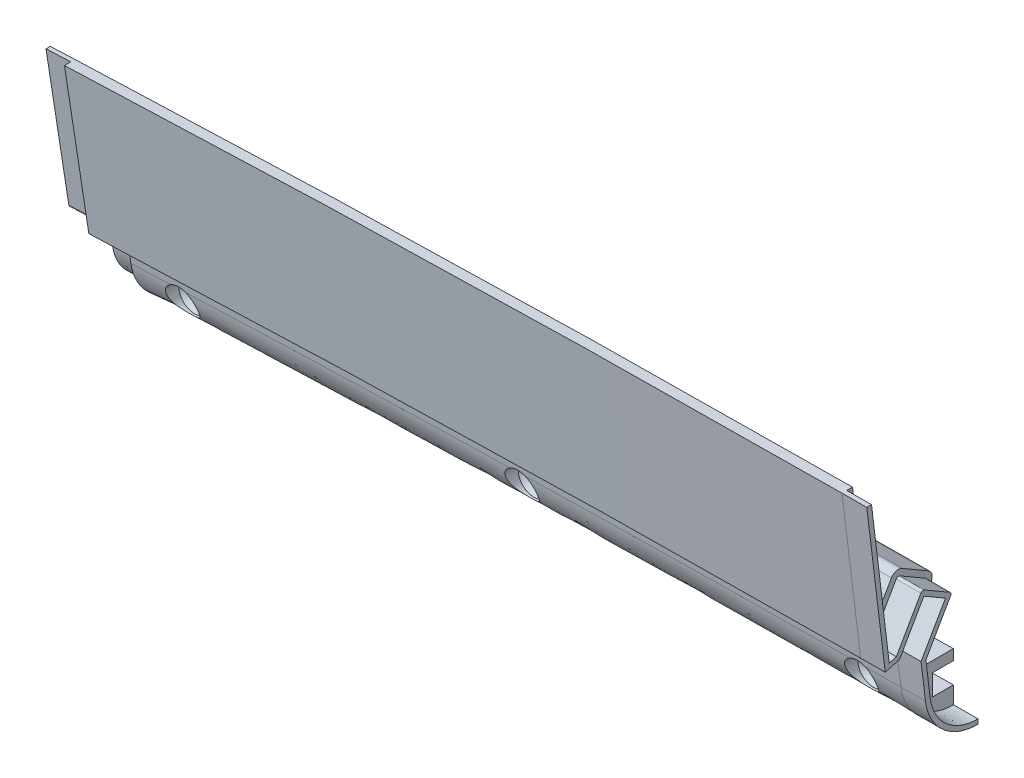
from build123d import *


with BuildPart() as part:
    # Sweep3: sweep along a path in Sketch3
    with BuildLine(Plane.XY.offset(101.6)) as sweep3_path:
        ThreePointArc((622.103936151, -83.199836272), (0, -43.636564626), (-622.103936151, -83.199836272))
    # Sketch4 → Sweep3 (sweep)
    with BuildSketch(Plane(origin=(-117.330566703, 4.430423936, 1117.6), x_dir=(0, 0, -1), z_dir=(0.9994536405585157, 0.03305178322465143, 0))):
        with BuildLine():
            Line((991.529482971, -5.453775083), (988.971801376, -5.453775083))
            Line((988.971801376, -5.453775083), (993.32506615, -42.283775083))
            Line((993.32506615, -42.283775083), (996.794703229, -41.354088728))
            Line((996.794703229, -41.354088728), (1002.763703229, -31.015013775))
            Line((1002.763703229, -31.015013775), (1007.999, -34.037749136))
            Line((1007.999, -34.037749136), (1002.03, -44.376824659))
            Line((1002.03, -44.376824659), (1003.077032208, -53.235049058))
            ThreePointArc((1003.077032208, -53.235049058), (1007.29752688, -61.276835992), (1015.8095, -64.443731312))
            Line((1015.8095, -64.443731312), (1015.8095, -59.12218153))
            Line((1015.8095, -59.12218153), (1010.7295, -59.12218153))
            Line((1010.7295, -59.12218153), (1010.7295, -54.041969025))
            Line((1010.7295, -54.041969025), (1015.8095, -54.041969025))
            Line((1015.8095, -54.041969025), (1015.8095, -51.501969025))
            Line((1015.8095, -51.501969025), (1007.687322123, -51.501969025))
            ThreePointArc((1007.687322123, -51.501969025), (1005.99997215, -50.860507955), (1005.164881483, -49.260118685))
            Line((1005.164881483, -49.260118685), (1004.750455768, -45.75394576))
            ThreePointArc((1004.750455768, -45.75394576), (1004.7850335, -44.943801809), (1005.073167189, -44.18583887))
            Line((1005.073167189, -44.18583887), (1010.516206197, -34.757795418))
            ThreePointArc((1010.516206197, -34.757795418), (1010.706497969, -33.312277166), (1009.818941274, -32.155567572))
            Line((1009.818941274, -32.155567572), (1003.483804566, -28.49781089))
            ThreePointArc((1003.483804566, -28.49781089), (1002.038222268, -28.307482122), (1000.881475684, -29.195102853))
            Line((1000.881475684, -29.195102853), (999.272416391, -31.982200293))
            ThreePointArc((999.272416391, -31.982200293), (996.560692883, -33.200105913), (994.550246564, -31.010392672))
            Line((994.550246564, -31.010392672), (991.529482971, -5.453775083))
        make_face()
    sweep(path=sweep3_path.line)

    # SurfaceCut1
    split(bisect_by=Plane(origin=(-211.442164364, -9.040193423, 0), x_dir=(0.04271589869142412, -0.9990872594518379, 0), z_dir=(-0.9990872594518379, -0.04271589869142412, 0)), keep=Keep.BOTTOM)

    # SurfaceCut2
    split(bisect_by=Plane(origin=(-22.599527872, -0.103088244, 0), x_dir=(-0.00456147456524855, 0.9999895964207781, 0), z_dir=(0.9999895964207781, 0.00456147456524855, 0)), keep=Keep.BOTTOM)

    # Sketch8 → Cut-Revolve1 (revolve, cut)
    with BuildSketch(Plane(origin=(-117.056038996, -3.871025798, 0), x_dir=(0, 0, -1), z_dir=(0.9994536405585157, 0.03305178322465143, 0)), mode=Mode.PRIVATE) as cut_revolve1_sk:
        Polygon((-119.5705, -48.27608749), (-106.8705, -48.27608749), (-106.8705, -46.37108749), (-108.7755, -46.37108749), (-110.6805, -44.46608749), (-119.5705, -44.46608749), align=None)
    cut_revolve1 = revolve(cut_revolve1_sk.sketch.rotate(Axis((-115.460428217, -52.120737191, 119.5705), (0, 0, -1)), 91.894072645), axis=Axis((-115.460428217, -52.120737191, 119.5705), (0, 0, -1)), mode=Mode.SUBTRACT)

    # Sketch-Pattern1: Cut-Revolve1 at 2 more places
    with Locations((82.543476, 1.248991, 0), (-82.510753, -2.638363, 0)):
        add(cut_revolve1, mode=Mode.SUBTRACT)

    # Sweep4: sweep along a path in Sketch12
    with BuildLine(Plane(origin=(0, 0, 101.7905), x_dir=(-1, 0, 0), z_dir=(0, 0, -1))) as sweep4_path:
        ThreePointArc((22.391388502, -45.732457057), (19.406892089, -45.719750506), (16.422388502, -45.708858513))
    # Sketch11 → Sweep4 (sweep)
    with BuildSketch(Plane(origin=(-22.599527872, -0.103088244, 0), x_dir=(0, 0, -1), z_dir=(0.9999895964207782, 0.0045614745652485505, 0))):
        with BuildLine():
            Line((-127.477241199, 0.416291674), (-123.294888708, -34.966157226))
            Line((-123.294888708, -34.966157226), (-121.558436986, -34.500897353))
            Line((-121.558436986, -34.500897353), (-115.572163807, -24.132368061))
            ThreePointArc((-115.572163807, -24.132368061), (-115.18658777, -23.836505161), (-114.704737676, -23.899941929))
            Line((-114.704737676, -23.899941929), (-108.589559095, -27.430541929))
            ThreePointArc((-108.589559095, -27.430541929), (-108.293696195, -27.816117967), (-108.357132963, -28.297968061))
            Line((-108.357132963, -28.297968061), (-114.390345193, -38.747798175))
            Line((-114.390345193, -38.747798175), (-113.38787021, -47.228671998))
            add(Edge.make_bspline(
                [(-113.38787021, -47.228671998), (-113.304795542, -47.931478283), (-113.005394664, -49.331413505), (-111.931567303, -51.922229671), (-109.715936846, -54.745652619), (-106.035083238, -56.94650453), (-103.201893406, -57.441334387), (-101.801323322, -57.428071482)],
                knots=[0, 0, 0, 0, 0.125, 0.25, 0.5, 0.75, 1, 1, 1, 1], degree=3))
            Line((-101.801323322, -57.428071482), (-101.7905, -57.428071482))
            Line((-101.7905, -57.428071482), (-101.7905, -58.571020236))
            add(Edge.make_bspline(
                [(-114.522967792, -47.362845321), (-114.477136038, -47.75057897), (-114.413580033, -48.135193314), (-114.251122313, -48.898201482), (-114.152305696, -49.275575056), (-113.807619255, -50.383408995), (-113.512952594, -51.094578165), (-112.794349261, -52.46234614), (-112.366195112, -53.122316961), (-111.411403795, -54.334839512), (-110.882225451, -54.894118535), (-110.009875034, -55.661739075), (-109.70425095, -55.906767732), (-109.076570448, -56.364164676), (-108.75418736, -56.57709785), (-107.762018779, -57.169725703), (-107.067422067, -57.503632754), (-105.974437358, -57.910210424), (-105.601773783, -58.029584478), (-104.85459633, -58.231768654), (-104.478193263, -58.315333853), (-103.340677537, -58.514298854), (-102.571330027, -58.578414422), (-101.7905, -58.571020236)],
                knots=[0, 0, 0, 0, 0.0625, 0.0625, 0.125, 0.125, 0.25, 0.25, 0.375, 0.375, 0.5, 0.5, 0.5625, 0.5625, 0.625, 0.625, 0.75, 0.75, 0.8125, 0.8125, 0.875, 0.875, 1, 1, 1, 1], degree=3))
            Line((-114.522967792, -47.362845321), (-115.57, -38.505020236))
            Line((-115.57, -38.505020236), (-109.601, -28.166408966))
            Line((-109.601, -28.166408966), (-114.836296771, -25.143808966))
            Line((-114.836296771, -25.143808966), (-120.805296771, -35.482420236))
            Line((-120.805296771, -35.482420236), (-124.27493385, -36.412064801))
            Line((-124.27493385, -36.412064801), (-128.628198624, 0.416291674))
            Line((-128.628198624, 0.416291674), (-127.477241199, 0.416291674))
        make_face()
    sweep(path=sweep4_path.line)

    # Sweep5: sweep along a path in Sketch16
    with BuildLine(Plane(origin=(0, 0, 101.7905), x_dir=(-1, 0, 0), z_dir=(0, 0, -1))) as sweep5_path:
        ThreePointArc((215.647406705, -50.42045008), (212.665748146, -50.290245196), (209.684010975, -50.161853153))
    # Sketch15 → Sweep5 (sweep)
    with BuildSketch(Plane(origin=(-211.442164364, -9.040193423, 0), x_dir=(0, 0, 1), z_dir=(-0.9990872594518379, -0.04271589869142412, 0))):
        with BuildLine():
            Line((113.00950435, -42.713331456), (113.97237291, -34.567525415))
            ThreePointArc((113.97237291, -34.567525415), (113.963727961, -34.364981701), (113.891689273, -34.175484686))
            Line((113.891689273, -34.175484686), (107.519177285, -23.137970149))
            Line((107.519177285, -23.137970149), (115.394119486, -18.591370149))
            Line((115.394119486, -18.591370149), (121.677968823, -29.475316467))
            ThreePointArc((121.677968823, -29.475316467), (121.841334284, -29.661598015), (122.06355177, -29.771181218))
            Line((122.06355177, -29.771181218), (122.259394286, -29.823654698))
            ThreePointArc((122.259394286, -29.823654698), (122.780015415, -29.735923875), (123.054347243, -29.284830643))
            Line((123.054347243, -29.284830643), (127.093588723, 4.886907775))
            Line((127.093588723, 4.886907775), (126.070517029, 4.886907775))
            Line((126.070517029, 4.886907775), (123.049753436, -20.668571968))
            add(Edge.make_bspline(
                [(123.049753436, -20.668571968), (123.018406598, -20.933764287), (122.944898871, -21.192703381), (122.72486191, -21.671025374), (122.574983618, -21.89613649), (122.218479429, -22.283693321), (122.006878086, -22.451668909), (121.662818096, -22.646204147), (121.543504304, -22.701961436), (121.295473201, -22.795007288), (121.166493424, -22.832124521), (120.907997451, -22.885096572), (120.777385583, -22.901432856), (120.51342226, -22.913717924), (120.37910716, -22.909438417), (120.116311005, -22.880334184), (119.986998098, -22.855691982), (119.732512188, -22.786374688), (119.606266969, -22.741161694), (119.243601748, -22.578043456), (119.021351761, -22.432970621), (118.626712377, -22.076251458), (118.461102845, -21.871598209), (118.327583609, -21.640336089)],
                knots=[0, 0, 0, 0, 0.125, 0.125, 0.25, 0.25, 0.375, 0.375, 0.4375, 0.4375, 0.5, 0.5, 0.5625, 0.5625, 0.625, 0.625, 0.6875, 0.6875, 0.75, 0.75, 0.875, 0.875, 1, 1, 1, 1], degree=3))
            Line((118.327583609, -21.640336089), (116.718524316, -18.853363359))
            ThreePointArc((116.718524316, -18.853363359), (115.561765682, -17.965779092), (114.116195434, -18.156102576))
            Line((114.116195434, -18.156102576), (107.781058726, -21.813695606))
            ThreePointArc((107.781058726, -21.813695606), (106.893505265, -22.97034131), (107.083793803, -24.415806877))
            Line((107.083793803, -24.415806877), (112.526832811, -33.84342694))
            ThreePointArc((112.526832811, -33.84342694), (112.814966033, -34.601353512), (112.849544232, -35.411463252))
            Line((112.849544232, -35.411463252), (112.435118517, -38.917478209))
            ThreePointArc((112.435118517, -38.917478209), (111.600006373, -40.51781438), (109.912677877, -41.159227425))
            Line((109.912677877, -41.159227425), (101.7905, -41.159227425))
            Line((101.7905, -41.159227425), (101.7905, -43.699112741))
            Line((101.7905, -43.699112741), (106.8705, -43.699112741))
            Line((106.8705, -43.699112741), (106.8705, -48.779095512))
            Line((106.8705, -48.779095512), (101.7905, -48.779095512))
            Line((101.7905, -48.779095512), (101.7905, -52.576472462))
            Line((101.7905, -52.576472462), (101.804931097, -52.576472462))
            add(Edge.make_bspline(
                [(101.804931097, -52.576472462), (102.489279498, -52.582953001), (103.868868527, -52.467414443), (106.485766193, -51.75509811), (109.465837716, -49.976138537), (112.028433947, -46.715360308), (112.850511097, -44.058404026), (113.00950435, -42.713331456)],
                knots=[0, 0, 0, 0, 0.125, 0.25, 0.5, 0.75, 1, 1, 1, 1], degree=3))
        make_face()
    sweep(path=sweep5_path.line)


solid = part.part
